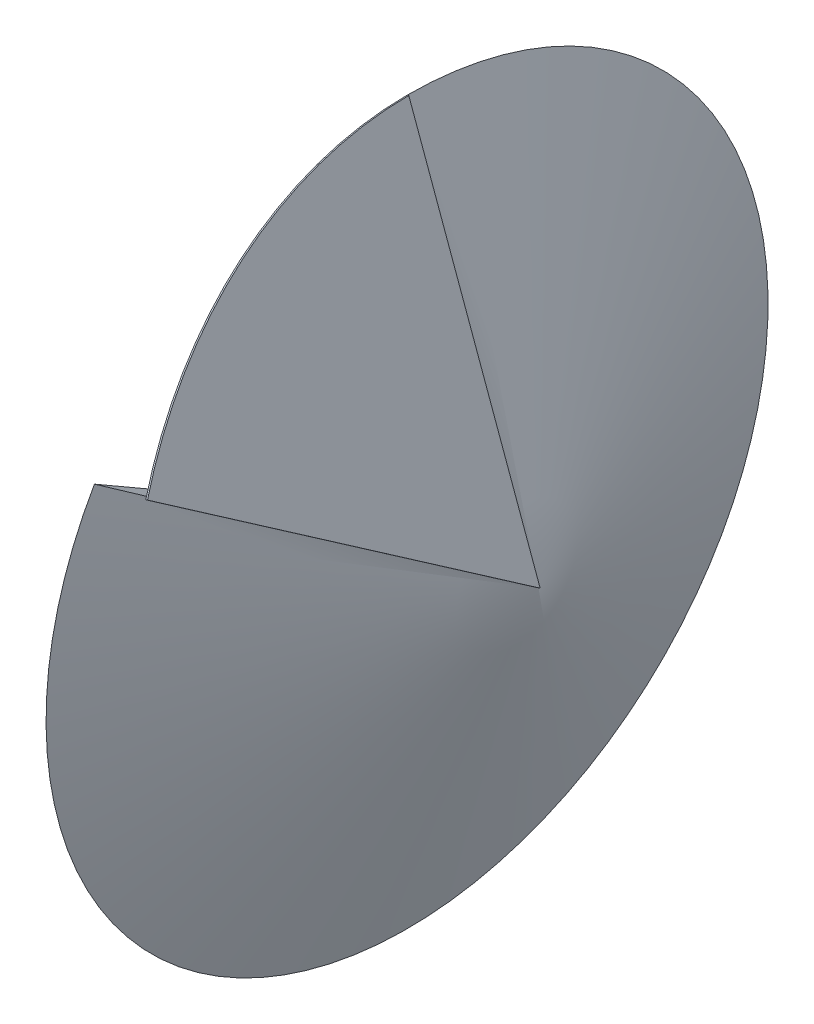
from build123d import *

# Parameters (mm, degrees)
R_VOLUTION1_ANGLE = 300
EXTRUSION1_DEPTH  = 1


with BuildPart() as part:
    # Esquisse1 → R_volution1 (revolve)
    with BuildSketch(Plane.XY):
        Polygon((0, 0), (72.794046853, 0), (0, 200), align=None)
    revolve(axis=Axis((0, 0, 0), (-1, 0, 0)), revolution_arc=R_VOLUTION1_ANGLE)

    # Esquisse2 → Extrusion1 (add)
    with BuildSketch(Plane(origin=(64.278760969, 23.395555688, 0), x_dir=(0, 0, -1), z_dir=(0.939692621, 0.342020143, 0))):
        with BuildLine():
            Line((0, -24.897030338), (-177.234129854, 92.946240459))
            ThreePointArc((-177.234129854, 92.946240459), (-100.542864923, 162.693229458), (0, 187.938524157))
            Line((0, 187.938524157), (0, -24.897030338))
        make_face()
    extrude(amount=EXTRUSION1_DEPTH)


solid = part.part
